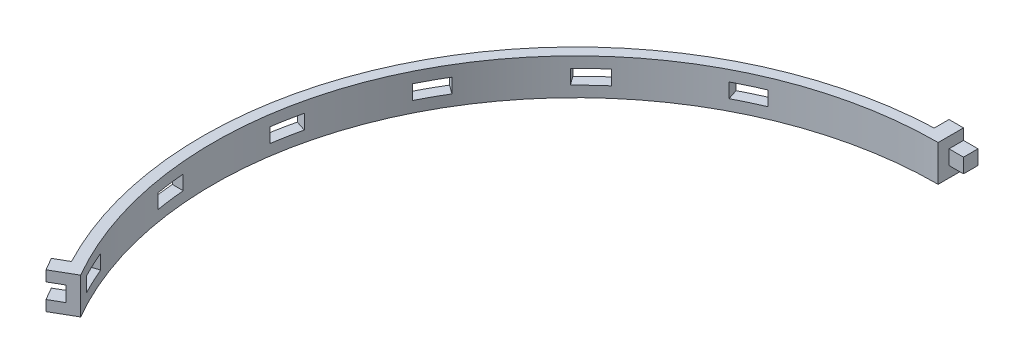
from build123d import *

# Parameters (mm, degrees)
BOSS_EXTRUDE1_DEPTH             = 10
SKETCH2_W                       = 8
SKETCH2_H                       = 4.2
CUT_EXTRUDE1_DEPTH              = 4
SKETCH3_W                       = 8
SKETCH3_H                       = 4
BOSS_EXTRUDE2_DEPTH             = 4
SKETCH4_W                       = 8
SKETCH4_H                       = 4
CUT_EXTRUDE2_DEPTH              = 104
CIRPATTERN4_COUNT               = 5
CIRPATTERN4_ANGLE               = 72
CIRPATTERN4_THE_OTHER_WAY_COUNT = 5
CIRPATTERN4_THE_OTHER_WAY_ANGLE = 72


with BuildPart() as part:
    # Sketch1 → Boss-Extrude1 (new body)
    with BuildSketch(Plane(origin=(0, 0, 0), x_dir=(1, 0, 0), z_dir=(0, 1, 0))):
        with BuildLine():
            Line((-4, 107), (-4, 102.92230079))
            ThreePointArc((-4, 102.92230079), (-89.20061659, 51.5), (-91.1333271, -47.99704878))
            Line((-91.1333271, -47.99704878), (-94.664718205, -50.035898385))
            Line((-94.664718205, -50.035898385), (-92.664718205, -53.5))
            Line((-92.664718205, -53.5), (-86.602540378, -50))
            ThreePointArc((-86.602540378, -50), (-86.602540378, 50), (0, 100))
            Line((0, 100), (0, 107))
            Line((0, 107), (-4, 107))
        make_face()
    extrude(amount=BOSS_EXTRUDE1_DEPTH)

    # Sketch2 → Cut-Extrude1 (cut)
    with BuildSketch(Plane(origin=(-92.664718205, 0, 53.5), x_dir=(0.5, 0, 0.866025404), z_dir=(-0.866025404, 0, 0.5))):
        with Locations((0, 5)):
            Rectangle(SKETCH2_W, SKETCH2_H)
    extrude(amount=-CUT_EXTRUDE1_DEPTH, mode=Mode.SUBTRACT)

    # Sketch3 → Boss-Extrude2 (add)
    with BuildSketch(Plane(origin=(0, 0, -107), x_dir=(-1, 0, 0), z_dir=(0, 0, -1))):
        with Locations((0, 5)):
            Rectangle(SKETCH3_W, SKETCH3_H)
    extrude(amount=-BOSS_EXTRUDE2_DEPTH)

    # Sketch4 → Cut-Extrude2 (cut, through all)
    with BuildSketch(Plane(origin=(0, 0, 0), x_dir=(0, 0, -1), z_dir=(1, 0, 0))):
        with Locations((-12.672320837, 5)):
            Rectangle(SKETCH4_W, SKETCH4_H)
    cut_extrude2 = extrude(amount=-CUT_EXTRUDE2_DEPTH, mode=Mode.SUBTRACT)

    # CirPattern4: Cut-Extrude2 ×5 about axis
    cirpattern4_axis = Axis((0, 0, 0), (0, -1, 0))
    for i in range(1, CIRPATTERN4_COUNT):
        add(cut_extrude2.rotate(cirpattern4_axis, i * CIRPATTERN4_ANGLE / (CIRPATTERN4_COUNT - 1)), mode=Mode.SUBTRACT)

    # CirPattern4 the other way: Cut-Extrude2 ×5 about axis
    cirpattern4_the_other_way_axis = Axis((0, 0, 0), (0, 1, 0))
    for i in range(1, CIRPATTERN4_THE_OTHER_WAY_COUNT):
        add(cut_extrude2.rotate(cirpattern4_the_other_way_axis, i * CIRPATTERN4_THE_OTHER_WAY_ANGLE / (CIRPATTERN4_THE_OTHER_WAY_COUNT - 1)), mode=Mode.SUBTRACT)


solid = part.part
